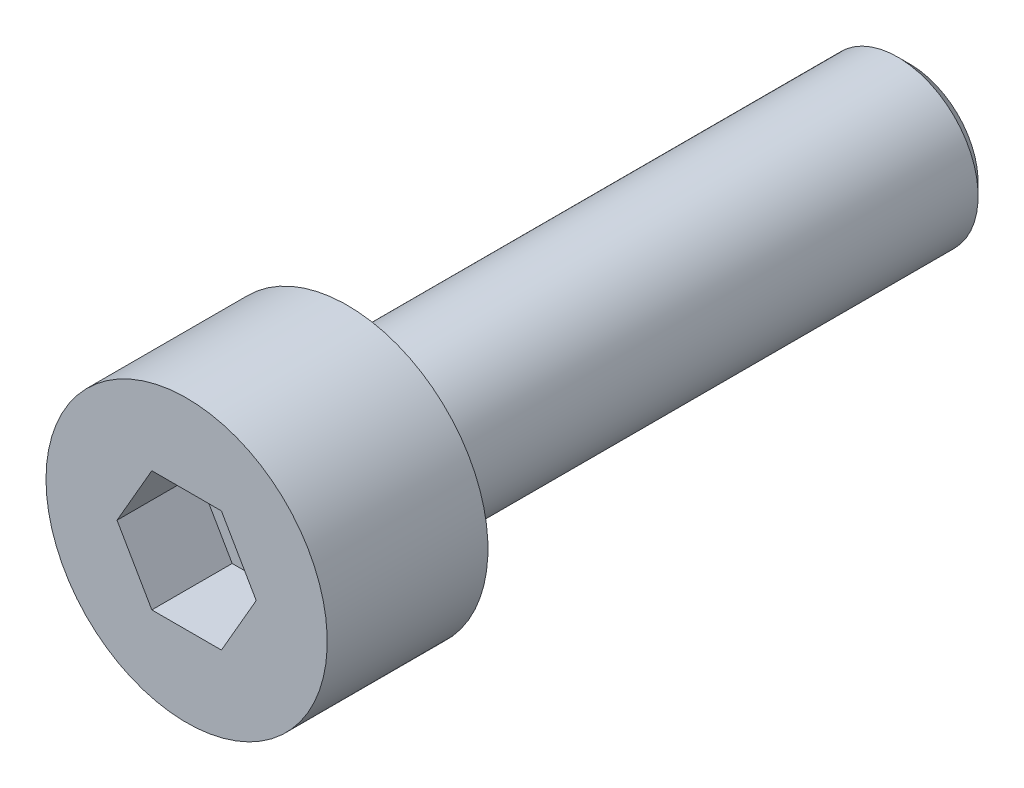
from build123d import *

# Parameters (mm, degrees)
CUT_EXTRUDE_1_DEPTH = 2
FILLET_1_R          = 0.3
CHAMFER_1_SIZE      = 0.3


with BuildPart() as part:
    # Эскиз1 → Повернуть1 (revolve)
    with BuildSketch(Plane(origin=(0, 0, 0), x_dir=(0, 0, -1), z_dir=(1, 0, 0))):
        Polygon((0, 0), (0, 3.5), (4, 3.5), (4, 2), (18, 2), (18, 0), align=None)
    revolve(axis=Axis((0, 0, 0), (0, 0, 1)))

    # Эскиз2 → Вырез-Вытянуть1 (cut)
    with BuildSketch(Plane.XY):
        Polygon((1.732050808, 0), (0.866025404, 1.5), (-0.866025404, 1.5), (-1.732050808, 0), (-0.866025404, -1.5), (0.866025404, -1.5), align=None)
    extrude(amount=-CUT_EXTRUDE_1_DEPTH, mode=Mode.SUBTRACT)

    # Скругление1
    fillet_1_edges = [part.edges().sort_by_distance(p)[0] for p in [
        (0, -2, -4),
    ]]
    fillet(fillet_1_edges, radius=FILLET_1_R)

    # Фаска1
    chamfer_1_edges = [part.edges().sort_by_distance(p)[0] for p in [
        (0, -2, -18),
    ]]
    chamfer(chamfer_1_edges, length=CHAMFER_1_SIZE)


solid = part.part
